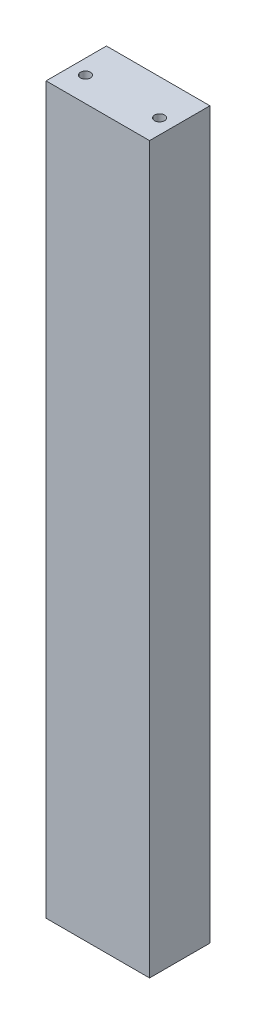
from build123d import *

# Parameters (mm, degrees)
SKETCH1_W                  = 41.91
SKETCH1_H                  = 24.4475
BOSS_EXTRUDE1_DEPTH        = 293.6875
F_10_32_TAPPED_HOLE1_D     = 4.0386
F_10_32_TAPPED_HOLE1_DEPTH = 18.796
F_10_32_TAPPED_HOLE1_TIP   = 1.213317848
F_10_32_TAPPED_HOLE3_D     = 4.0386
F_10_32_TAPPED_HOLE3_DEPTH = 18.796
F_10_32_TAPPED_HOLE3_TIP   = 1.213317848


with BuildPart() as part:
    # Sketch1 → Boss-Extrude1 (new body)
    with BuildSketch(Plane(origin=(0, 0, 0), x_dir=(1, 0, 0), z_dir=(0, 1, 0))):
        with Locations((20.955, 12.22375)):
            Rectangle(SKETCH1_W, SKETCH1_H)
    extrude(amount=BOSS_EXTRUDE1_DEPTH)

    # #10-32 Tapped Hole1
    with Locations(Plane(origin=(0, 293.6875, 0), x_dir=(-1, 0, 0), z_dir=(0, 1, 0))):
        with Locations((-5.955, -10), (-35.955, -10)):
            Hole(F_10_32_TAPPED_HOLE1_D / 2, depth=F_10_32_TAPPED_HOLE1_DEPTH)
            with Locations((0, 0, -(F_10_32_TAPPED_HOLE1_DEPTH + F_10_32_TAPPED_HOLE1_TIP / 2))):  # 118° drill point
                Cone(0, F_10_32_TAPPED_HOLE1_D / 2, F_10_32_TAPPED_HOLE1_TIP, mode=Mode.SUBTRACT)

    # #10-32 Tapped Hole3
    with Locations(Plane(origin=(51.003414264, 0, 2.457986719), x_dir=(1, 0, 0), z_dir=(0, -1, 0))):
        with Locations((-15.048414264, -12.457986785), (-45.048414264, -12.457986785)):
            Hole(F_10_32_TAPPED_HOLE3_D / 2, depth=F_10_32_TAPPED_HOLE3_DEPTH)
            with Locations((0, 0, -(F_10_32_TAPPED_HOLE3_DEPTH + F_10_32_TAPPED_HOLE3_TIP / 2))):  # 118° drill point
                Cone(0, F_10_32_TAPPED_HOLE3_D / 2, F_10_32_TAPPED_HOLE3_TIP, mode=Mode.SUBTRACT)


solid = part.part
